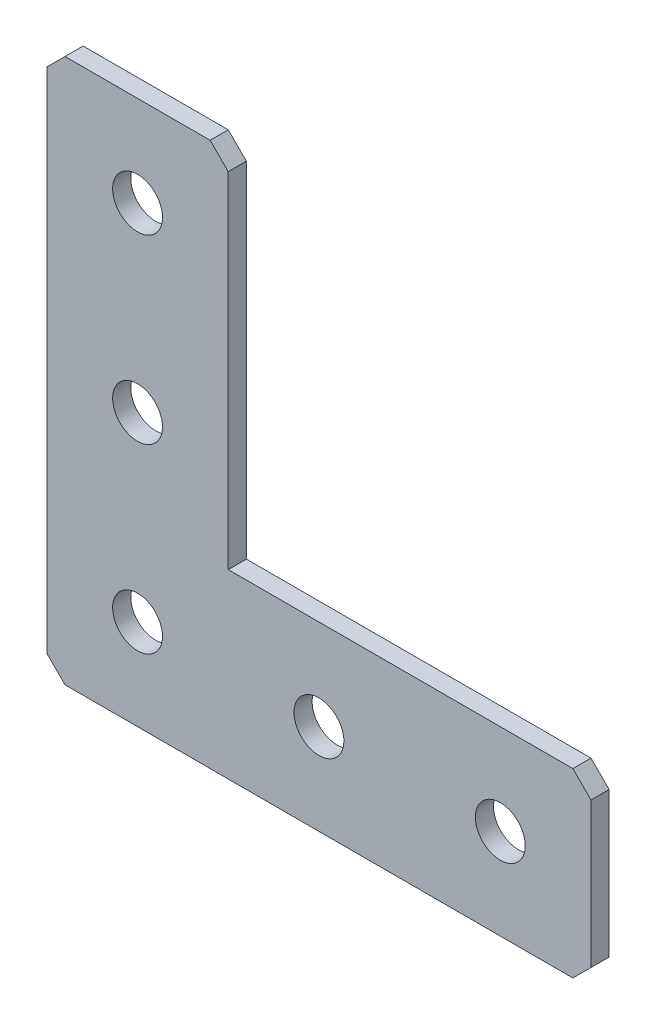
from build123d import *

# Parameters (mm, degrees)
EXTRUDE_1_DEPTH   = 2
HOLE_WIZARD_M51_D = 5.5
CHAMFER_1_SIZE    = 2


with BuildPart() as part:
    # Эскиз1 → Бобышка-Вытянуть1 (new body)
    with BuildSketch(Plane(origin=(0, 0, 0), x_dir=(1, 0, 0), z_dir=(0, 0, -1))):
        Polygon((0, 0), (0, 60), (60, 60), (60, 40), (20, 40), (20, 0), align=None)
    extrude(amount=EXTRUDE_1_DEPTH)

    # Отверстие с зазором M51 (through all)
    with Locations(Plane(origin=(0, 0, -2), x_dir=(1, 0, 0), z_dir=(0, 0, -1))):
        with Locations((30, 50), (10, 50), (10, 30), (10, 10), (50, 50)):
            Hole(HOLE_WIZARD_M51_D / 2)

    # Фаска1
    chamfer_1_edges = [part.edges().sort_by_distance(p)[0] for p in [
        (0, 0, -1),
        (0, -60, -1),
        (60, -60, -1),
        (60, -40, -1),
        (20, 0, -1),
    ]]
    chamfer(chamfer_1_edges, length=CHAMFER_1_SIZE)


solid = part.part
